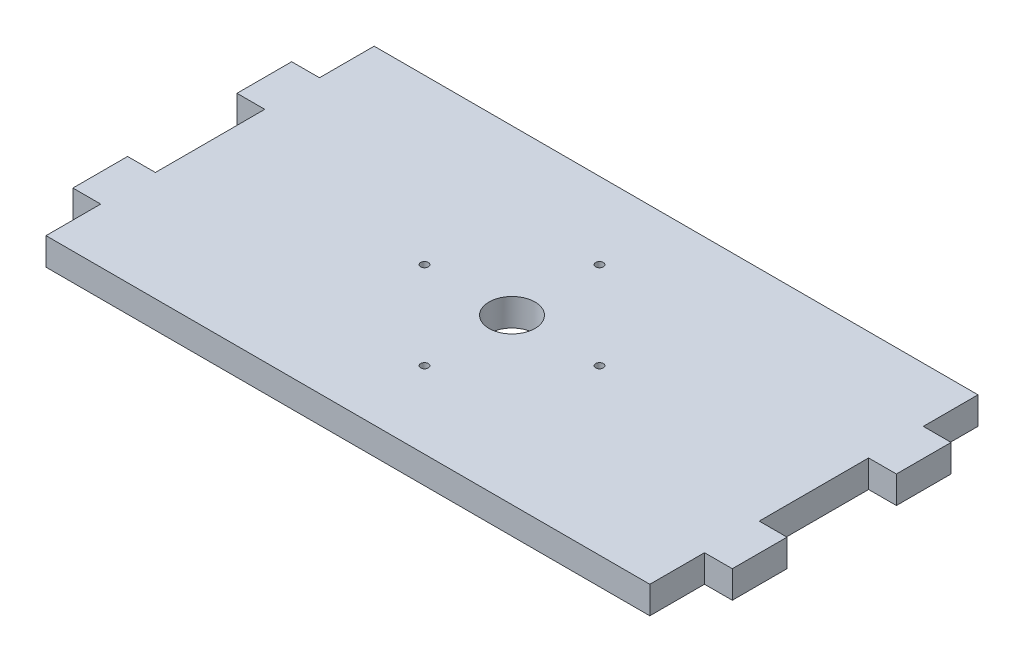
from build123d import *

# Parameters (mm, degrees)
SKETCH1_W                            = 70.104
SKETCH1_H                            = 38.1
BOSS_EXTRUDE1_DEPTH                  = 3.175
SKETCH2_W                            = 3.2258
SKETCH2_H                            = 6.35
BOSS_EXTRUDE2_DEPTH                  = 3.175
SKETCH4_R                            = 2.667
SKETCH4_R_2                          = 0.4445
CUT_FOR_SERVO_HORN_MOUNT_HOLES_DEPTH = 4.175


with BuildPart() as part:
    # Sketch1 → Boss-Extrude1 (new body)
    with BuildSketch(Plane(origin=(0, 0, 0), x_dir=(1, 0, 0), z_dir=(0, 1, 0))):
        Rectangle(SKETCH1_W, SKETCH1_H)
    extrude(amount=BOSS_EXTRUDE1_DEPTH)

    # Sketch2 → Boss-Extrude2 (add)
    with BuildSketch(Plane(origin=(0, 3.175, 0), x_dir=(1, 0, 0), z_dir=(0, 1, 0))):
        with Locations((36.6649, 9.525)):
            Rectangle(SKETCH2_W, SKETCH2_H)
        with Locations((36.6649, -9.525)):
            Rectangle(SKETCH2_W, SKETCH2_H)
    boss_extrude2 = extrude(amount=-BOSS_EXTRUDE2_DEPTH)

    # Mirror1: Boss-Extrude2 across plane
    add(boss_extrude2.mirror(Plane(origin=(0, 0, 0), x_dir=(0, 0, 1), z_dir=(1, 0, 0))))

    # Sketch4 → cut for servo horn mount holes (cut, through all)
    with BuildSketch(Plane(origin=(0, 3.175, 0), x_dir=(1, 0, 0), z_dir=(0, 1, 0))):
        Circle(SKETCH4_R)
        with Locations((0, 10.16)):
            Circle(SKETCH4_R_2)
        with Locations((10.16, 0)):
            Circle(SKETCH4_R_2)
        with Locations((0, -10.16)):
            Circle(SKETCH4_R_2)
        with Locations((-10.16, 0)):
            Circle(SKETCH4_R_2)
    extrude(amount=-CUT_FOR_SERVO_HORN_MOUNT_HOLES_DEPTH, mode=Mode.SUBTRACT)


solid = part.part
